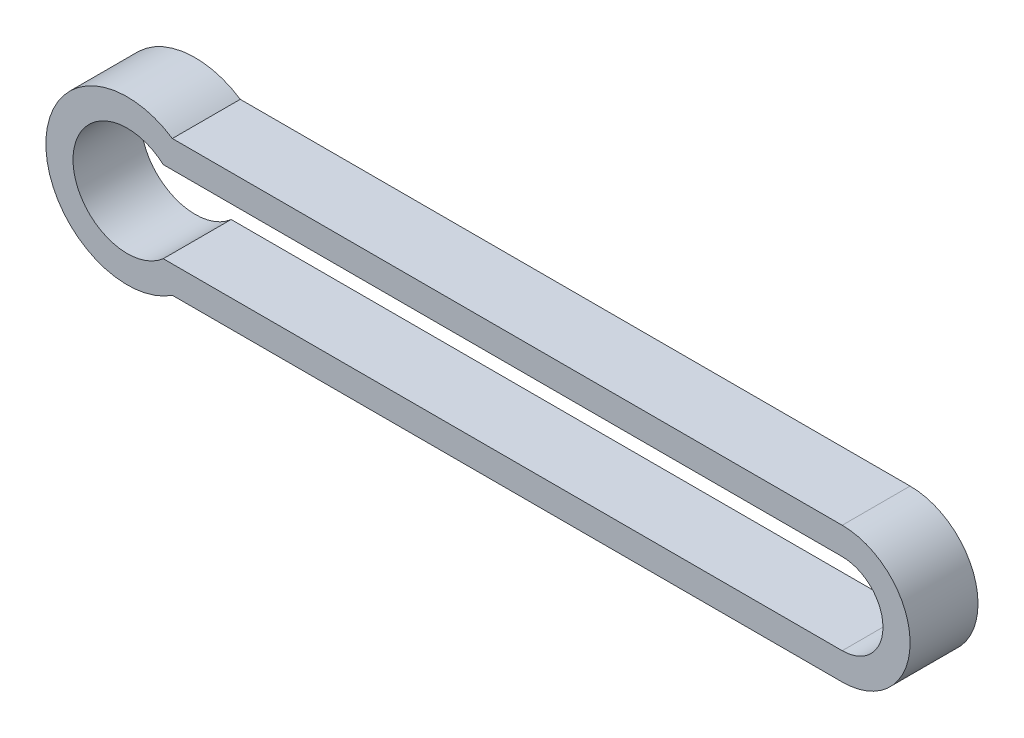
from build123d import *

# Parameters (mm, degrees)
EXTRUDE_1_DEPTH = 5


with BuildPart() as part:
    # 草图1 → 凸台-拉伸1 (new body)
    with BuildSketch(Plane.XY):
        with BuildLine():
            Line((52.645751311, -5), (3.31662479, -5))
            ThreePointArc((3.31662479, -5), (-6, 0), (3.31662479, 5))
            Line((3.31662479, 5), (52.645751311, 5))
            ThreePointArc((52.645751311, 5), (57.645751311, 0), (52.645751311, -5))
        make_face()
        with BuildLine():
            Line((2.645751311, 3), (52.645751311, 3))
            ThreePointArc((52.645751311, 3), (55.645751311, 0), (52.645751311, -3))
            Line((52.645751311, -3), (2.645751311, -3))
            ThreePointArc((2.645751311, -3), (-4, 0), (2.645751311, 3))
        make_face(mode=Mode.SUBTRACT)
    extrude(amount=EXTRUDE_1_DEPTH)


solid = part.part
